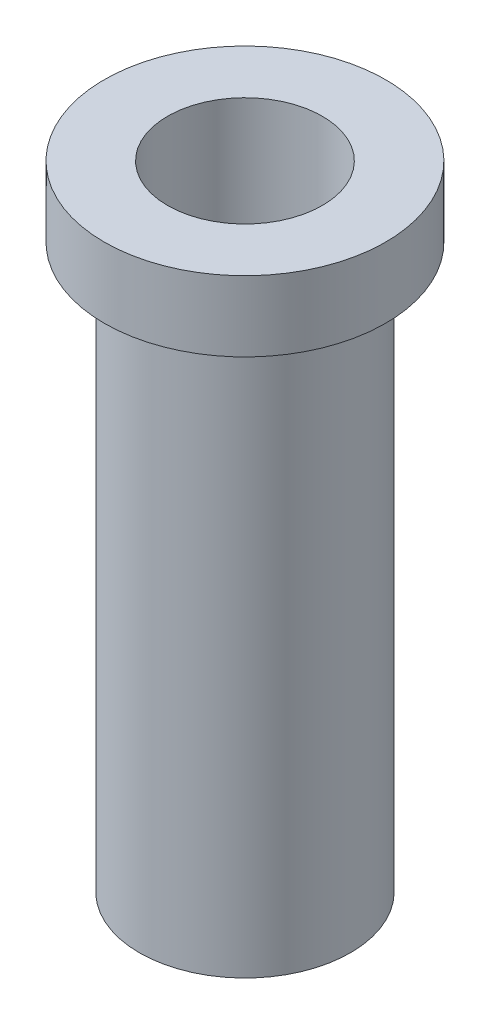
from build123d import *

# Parameters (mm, degrees)
SKETCH1_R           = 7.5
BOSS_EXTRUDE1_DEPTH = 40
SKETCH2_R           = 10
BOSS_EXTRUDE2_DEPTH = 5
CUT_EXTRUDE1_REACH  = 47
SKETCH3_R           = 5.5


with BuildPart() as part:
    # Sketch1 → Boss-Extrude1 (new body)
    with BuildSketch(Plane(origin=(0, 0, 0), x_dir=(1, 0, 0), z_dir=(0, 1, 0))):
        Circle(SKETCH1_R)
    extrude(amount=BOSS_EXTRUDE1_DEPTH)

    # Sketch2 → Boss-Extrude2 (add)
    with BuildSketch(Plane(origin=(0, 40, 0), x_dir=(1, 0, 0), z_dir=(0, 1, 0))):
        Circle(SKETCH2_R)
    extrude(amount=BOSS_EXTRUDE2_DEPTH)

    # Sketch3 → Cut-Extrude1 (cut, up to next)
    with BuildSketch(Plane(origin=(0, 45, 0), x_dir=(1, 0, 0), z_dir=(0, 1, 0)), mode=Mode.PRIVATE) as cut_extrude1_sk1:
        Circle(SKETCH3_R)
    cut_extrude1_tool1 = extrude(cut_extrude1_sk1.sketch, amount=-CUT_EXTRUDE1_REACH, mode=Mode.PRIVATE) & part.part
    add(cut_extrude1_tool1.solids().sort_by_distance((0, 45, 0))[0], mode=Mode.SUBTRACT)


solid = part.part
